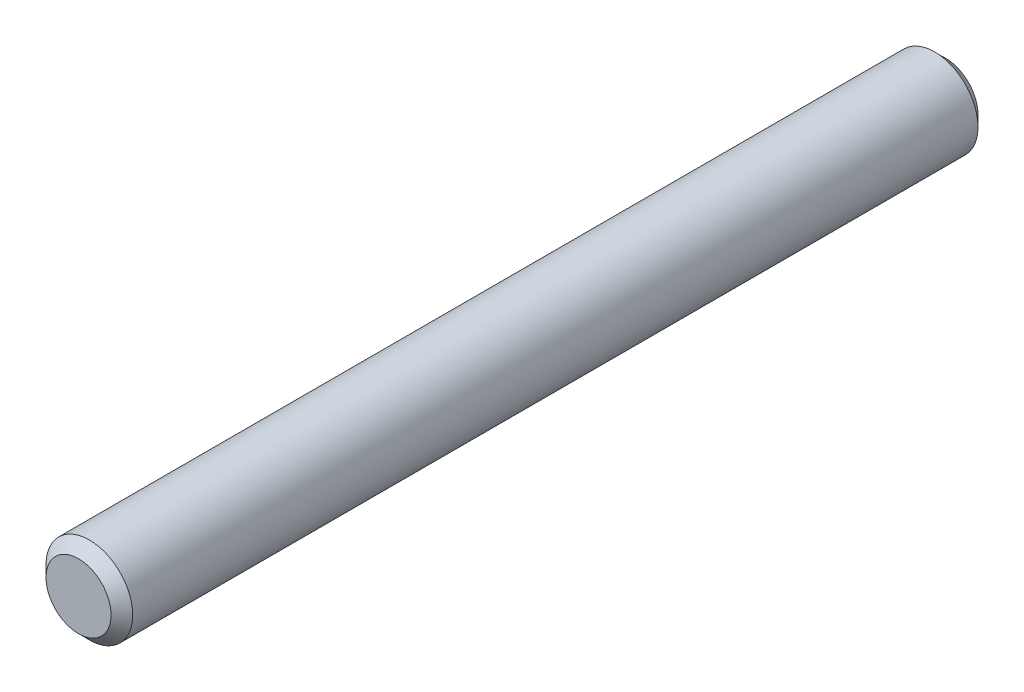
from build123d import *

# Parameters (mm, degrees)
SZKIC1_R                    = 4
DODANIE_WYCI_GNI_CIE1_DEPTH = 40
SFAZOWANIE1_SIZE            = 1


with BuildPart() as part:
    # Szkic1 → Dodanie-wyciągnięcie1 (new body, symmetric)
    with BuildSketch(Plane.XY):
        Circle(SZKIC1_R)
    extrude(amount=DODANIE_WYCI_GNI_CIE1_DEPTH, both=True)

    # Sfazowanie1
    sfazowanie1_edges = [part.edges().sort_by_distance(p)[0] for p in [
        (-4, 0, -40),
        (-4, 0, 40),
    ]]
    chamfer(sfazowanie1_edges, length=SFAZOWANIE1_SIZE)


solid = part.part
